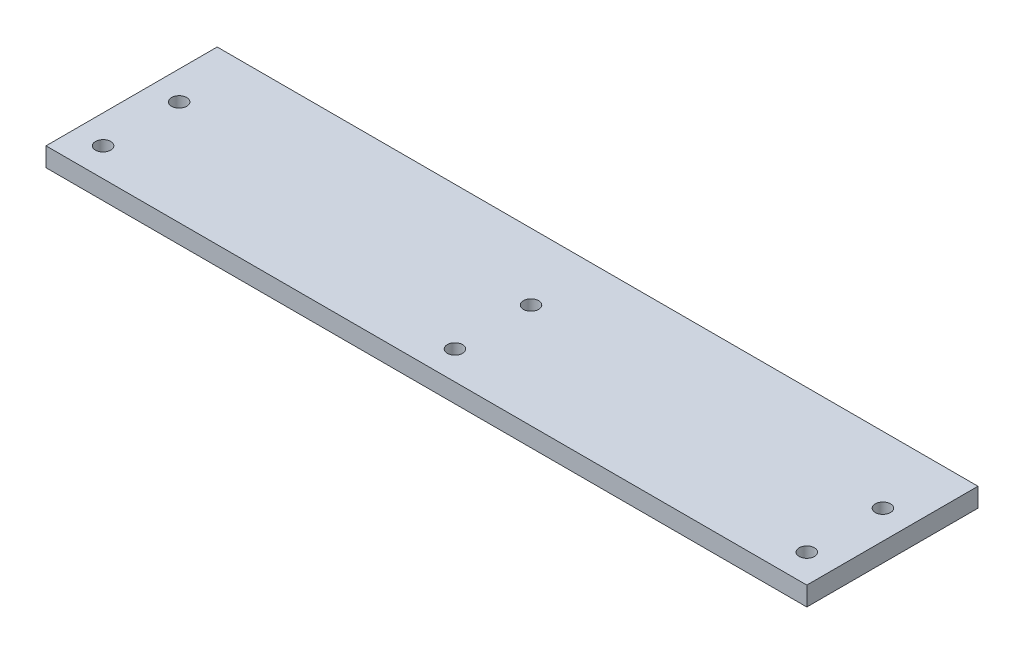
from build123d import *

# Parameters (mm, degrees)
SKETCH1_W           = 127
SKETCH1_H           = 25.4
SKETCH1_R           = 1.27
SKETCH1_H_2         = 3.175
BOSS_EXTRUDE1_DEPTH = 3.175


with BuildPart() as part:
    # Sketch1 → Boss-Extrude1 (new body)
    with BuildSketch(Plane(origin=(0, 0, 0), x_dir=(1, 0, 0), z_dir=(0, 1, 0))):
        Rectangle(SKETCH1_W, SKETCH1_H)
        with Locations((58.7375, -7.9375)):
            Circle(SKETCH1_R, mode=Mode.SUBTRACT)
        with Locations((0, -7.9375)):
            Circle(SKETCH1_R, mode=Mode.SUBTRACT)
        with Locations((-58.7375, -7.9375)):
            Circle(SKETCH1_R, mode=Mode.SUBTRACT)
        with Locations((58.7375, 4.7625)):
            Circle(SKETCH1_R, mode=Mode.SUBTRACT)
        with Locations((0, 4.7625)):
            Circle(SKETCH1_R, mode=Mode.SUBTRACT)
        with Locations((-58.7375, 4.7625)):
            Circle(SKETCH1_R, mode=Mode.SUBTRACT)
        with Locations((0, 14.2875)):
            Rectangle(SKETCH1_W, SKETCH1_H_2)
    extrude(amount=BOSS_EXTRUDE1_DEPTH)


solid = part.part
